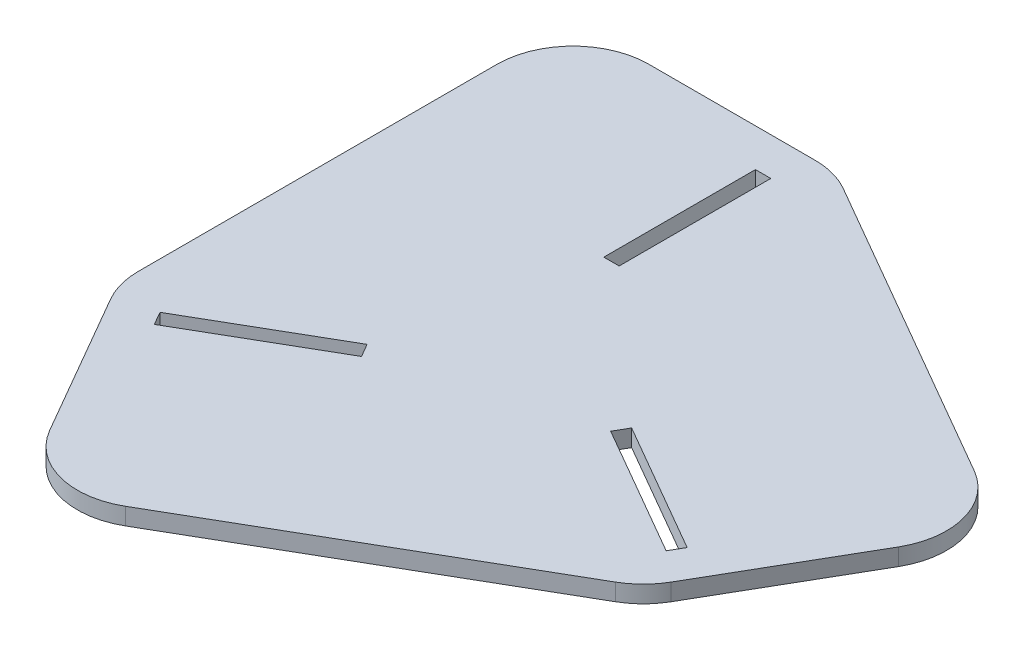
from build123d import *

# Parameters (mm, degrees)
SKETCH1_W           = 4.05
SKETCH1_H           = 40
BOSS_EXTRUDE1_DEPTH = 4.5
FILLET1_R           = 20


with BuildPart() as part:
    # Sketch1 → Boss-Extrude1 (new body)
    with BuildSketch(Plane(origin=(0, 0, 0), x_dir=(1, 0, 0), z_dir=(0, 1, 0))):
        Polygon((103.923048454, 20), (0, 80), (-69.282032303, 80), (-69.282032303, -40), (-34.641016151, -100), (69.282032303, -40), align=None)
        with Locations((-9.116016151, 50)):
            Rectangle(SKETCH1_W, SKETCH1_H, mode=Mode.SUBTRACT)
        Polygon((29.526270189, -8.858999874), (31.551270189, -5.351596989), (66.192286341, -25.351596989), (64.167286341, -28.858999874), align=None, mode=Mode.SUBTRACT)
        Polygon((-22.435254038, -21.141000126), (-20.410254038, -24.648403011), (-55.051270189, -44.648403011), (-57.076270189, -41.141000126), align=None, mode=Mode.SUBTRACT)
    extrude(amount=BOSS_EXTRUDE1_DEPTH)

    # Fillet1
    fillet1_edges = [part.edges().sort_by_distance(p)[0] for p in [
        (-69.282032303, 2.25, -80),
        (103.923048454, 2.25, -20),
        (-34.641016151, 2.25, 100),
        (69.282032303, 2.25, 40),
        (0, 2.25, -80),
        (-69.282032303, 2.25, 40),
    ]]
    fillet(fillet1_edges, radius=FILLET1_R)


solid = part.part
